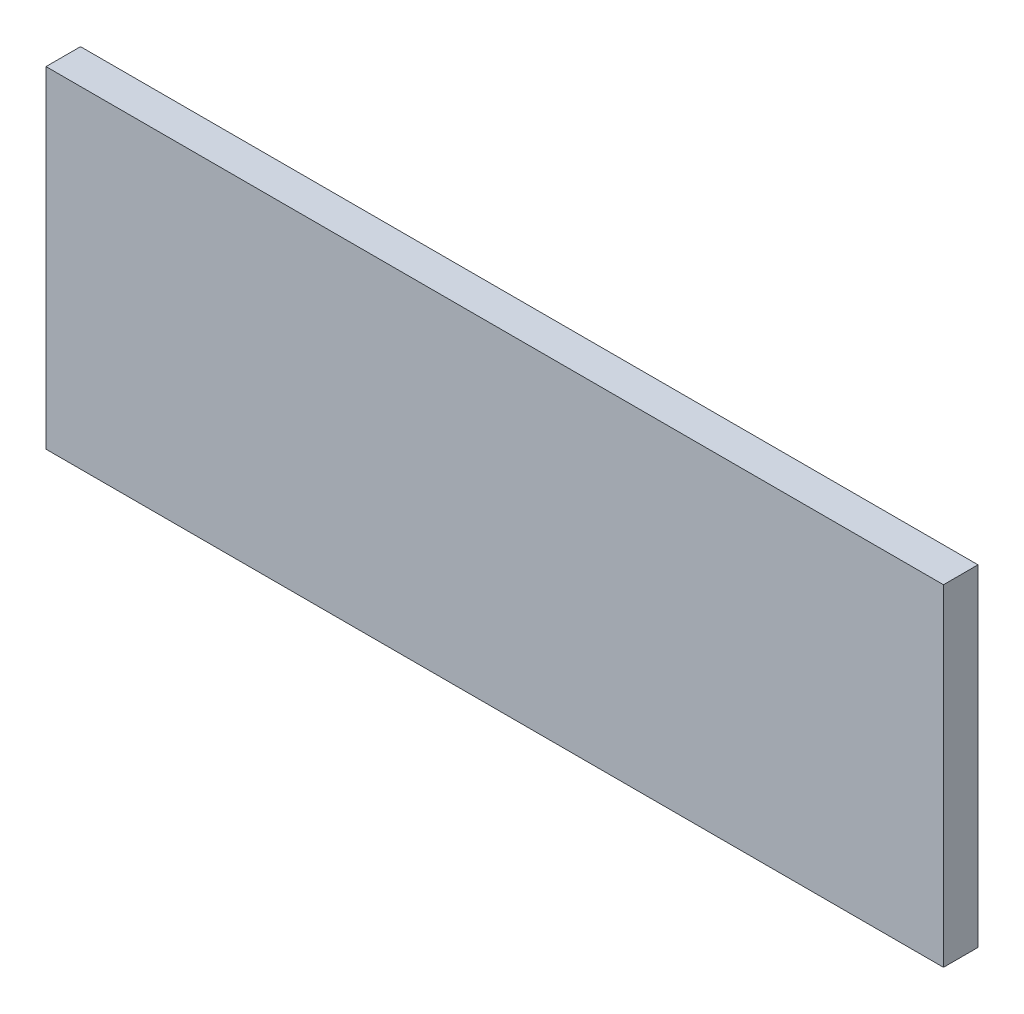
from build123d import *

# Parameters (mm, degrees)
SKETCH1_W           = 33.02
SKETCH1_H           = 12.192
BOSS_EXTRUDE1_DEPTH = 1.27


with BuildPart() as part:
    # Sketch1 → Boss-Extrude1 (new body)
    with BuildSketch(Plane.XY):
        with Locations((16.51, 6.096)):
            Rectangle(SKETCH1_W, SKETCH1_H)
    extrude(amount=BOSS_EXTRUDE1_DEPTH)


solid = part.part
